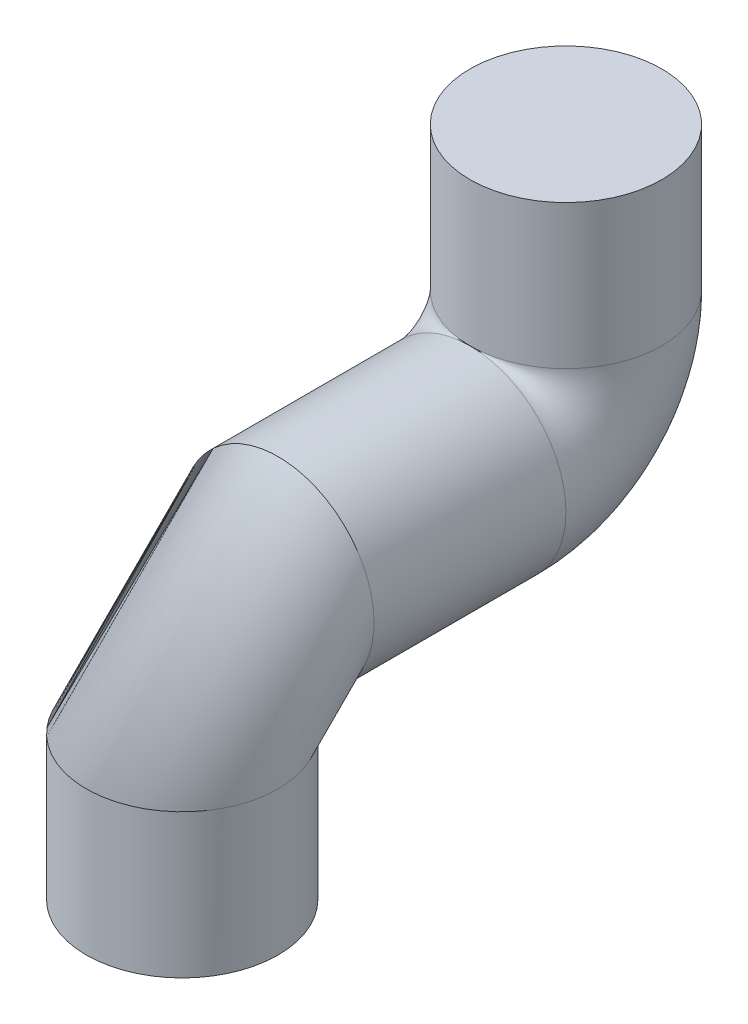
from build123d import *

# Parameters (mm, degrees)
SKETCH3_R          = 30
SKETCH4_R          = 20
CUT_EXTRUDE1_DEPTH = 10


with BuildPart() as part:
    # Sweep4: sweep along a path in Sketch1
    with BuildLine(Plane(origin=(0, 0, 0), x_dir=(0, 0, -1), z_dir=(1, 0, 0))) as sweep4_path:
        Line((60, 75), (60, 30))
        ThreePointArc((60, 30), (51.213203436, 8.786796564), (30, 0))
        Line((30, 0), (-30, 0))
        ThreePointArc((-30, 0), (-51.213203436, -8.786796564), (-60, -30))
        Line((-60, -30), (-60, -75))
    # Sketch3 → Sweep4 (sweep)
    with BuildSketch(Plane(origin=(0, 75, 0), x_dir=(1, 0, 0), z_dir=(0, 1, 0))):
        with Locations((0, 60)):
            Circle(SKETCH3_R)
    sweep(path=sweep4_path.line)

    # Sketch4 → Cut-Extrude1 (cut)
    with BuildSketch(Plane.XZ.offset(75)):
        with Locations((0, 60)):
            Circle(SKETCH4_R)
    extrude(amount=-CUT_EXTRUDE1_DEPTH, mode=Mode.SUBTRACT)


solid = part.part
